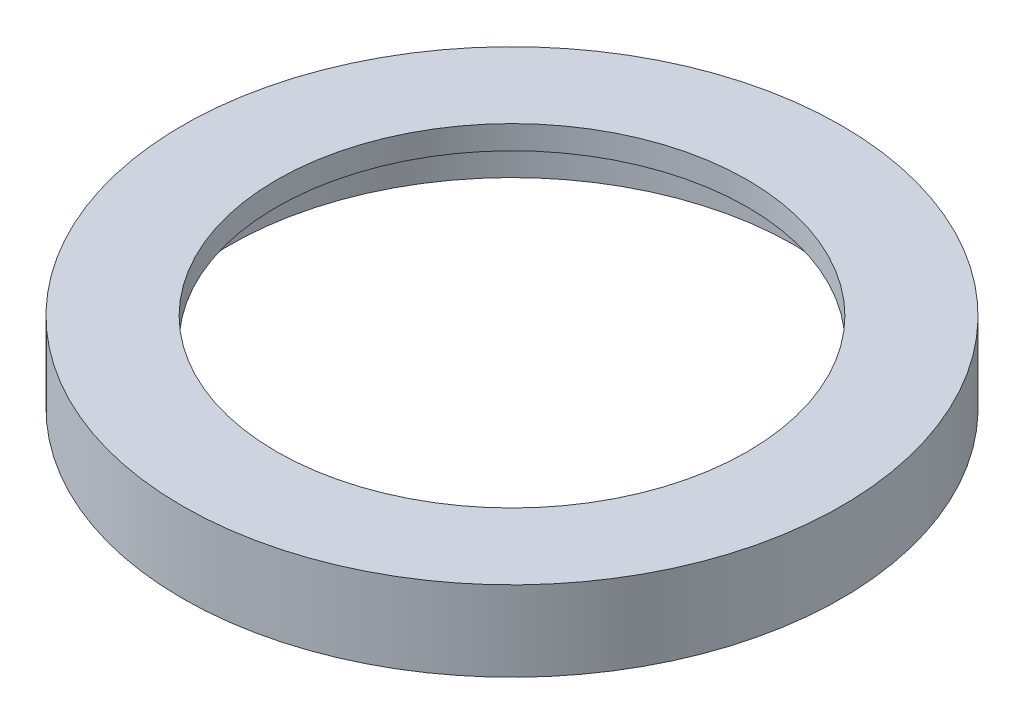
from build123d import *

# Parameters (mm, degrees)
SKETCH2_R           = 350
SKETCH2_R_2         = 250
BOSS_EXTRUDE1_DEPTH = 85
SKETCH3_R           = 300
CUT_EXTRUDE1_DEPTH  = 60


with BuildPart() as part:
    # Sketch2 → Boss-Extrude1 (new body)
    with BuildSketch(Plane(origin=(0, 0, 0), x_dir=(1, 0, 0), z_dir=(0, 1, 0))):
        Circle(SKETCH2_R)
        Circle(SKETCH2_R_2, mode=Mode.SUBTRACT)
    extrude(amount=BOSS_EXTRUDE1_DEPTH)

    # Sketch3 → Cut-Extrude1 (cut)
    with BuildSketch(Plane.XZ):
        Circle(SKETCH3_R)
    extrude(amount=-CUT_EXTRUDE1_DEPTH, mode=Mode.SUBTRACT)


solid = part.part
